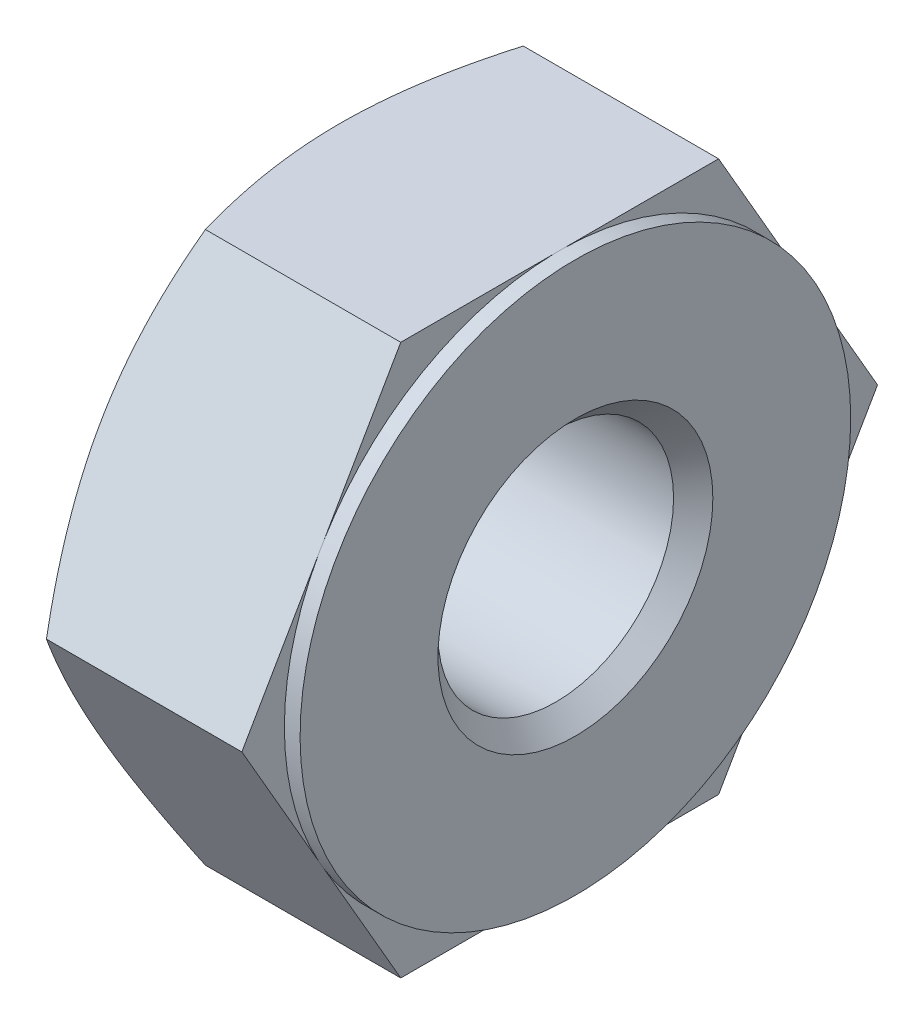
from build123d import *

# Parameters (mm, degrees)
CUT_EXTRUDE8_DEPTH   = 3.5
SKETCH16_R           = 3.505318085
BOSS_EXTRUDE10_DEPTH = 0.2
SKETCH17_R           = 1.5
CUT_EXTRUDE9_DEPTH   = 5
CHAMFER2_SIZE        = 0.25


with BuildPart() as part:
    # Sketch6 → Revolve10 (revolve)
    with BuildSketch(Plane(origin=(0, 0, 0), x_dir=(1, 0, 0), z_dir=(0, 1, 0))):
        Polygon((9.015233675, -1.950120561), (9.015233675, -5.996890529), (6.215233675, -5.996890529), (6.215233675, -2.491572445), (6.527841066, -1.950120561), align=None)
    revolve(axis=Axis((5.148806832, 0, 5.996890529), (1, 0, 0)))

    # Sketch14 → Cut-Extrude8 (cut)
    with BuildSketch(Plane(origin=(9.015233675, 0, 0), x_dir=(0, 0, -1), z_dir=(1, 0, 0))):
        with BuildLine():
            Line((-8.020275514, 3.504605596), (-3.973505545, 3.504605596))
            ThreePointArc((-3.973505545, 3.504605596), (-5.996890529, 4.046769969), (-8.020275514, 3.504605596))
        make_face()
        with BuildLine():
            Line((-10.043660498, 0), (-8.020275514, 3.504605596))
            ThreePointArc((-8.020275514, 3.504605596), (-9.501496126, 2.023384984), (-10.043660498, 0))
        make_face()
        with BuildLine():
            ThreePointArc((-10.043660498, 0), (-9.501496126, -2.023384984), (-8.020275514, -3.504605596))
            Line((-8.020275514, -3.504605596), (-10.043660498, 0))
        make_face()
        with BuildLine():
            ThreePointArc((-8.020275514, -3.504605596), (-5.996890529, -4.046769969), (-3.973505545, -3.504605596))
            Line((-3.973505545, -3.504605596), (-8.020275514, -3.504605596))
        make_face()
        with BuildLine():
            ThreePointArc((-3.973505545, -3.504605596), (-2.492284933, -2.023384984), (-1.950120561, 0))
            Line((-1.950120561, 0), (-3.973505545, -3.504605596))
        make_face()
        with BuildLine():
            Line((-3.973505545, 3.504605596), (-1.950120561, 0))
            ThreePointArc((-1.950120561, 0), (-2.492284933, 2.023384984), (-3.973505545, 3.504605596))
        make_face()
    extrude(amount=-CUT_EXTRUDE8_DEPTH, mode=Mode.SUBTRACT)

    # Sketch16 → Boss-Extrude10 (add)
    with BuildSketch(Plane(origin=(9.015233675, 0, 0), x_dir=(0, 0, -1), z_dir=(1, 0, 0))):
        with Locations((-5.996890529, 0)):
            Circle(SKETCH16_R)
    extrude(amount=BOSS_EXTRUDE10_DEPTH)

    # Sketch17 → Cut-Extrude9 (cut)
    with BuildSketch(Plane(origin=(9.215233675, 0, 0), x_dir=(0, 0, -1), z_dir=(1, 0, 0))):
        with Locations((-5.996890529, 0)):
            Circle(SKETCH17_R)
    extrude(amount=-CUT_EXTRUDE9_DEPTH, mode=Mode.SUBTRACT)

    # Chamfer2
    chamfer2_edges = [part.edges().sort_by_distance(p)[0] for p in [
        (6.215233675, 0, 7.496890529),
        (9.215233675, 0, 7.496890529),
    ]]
    chamfer(chamfer2_edges, length=CHAMFER2_SIZE)


solid = part.part
